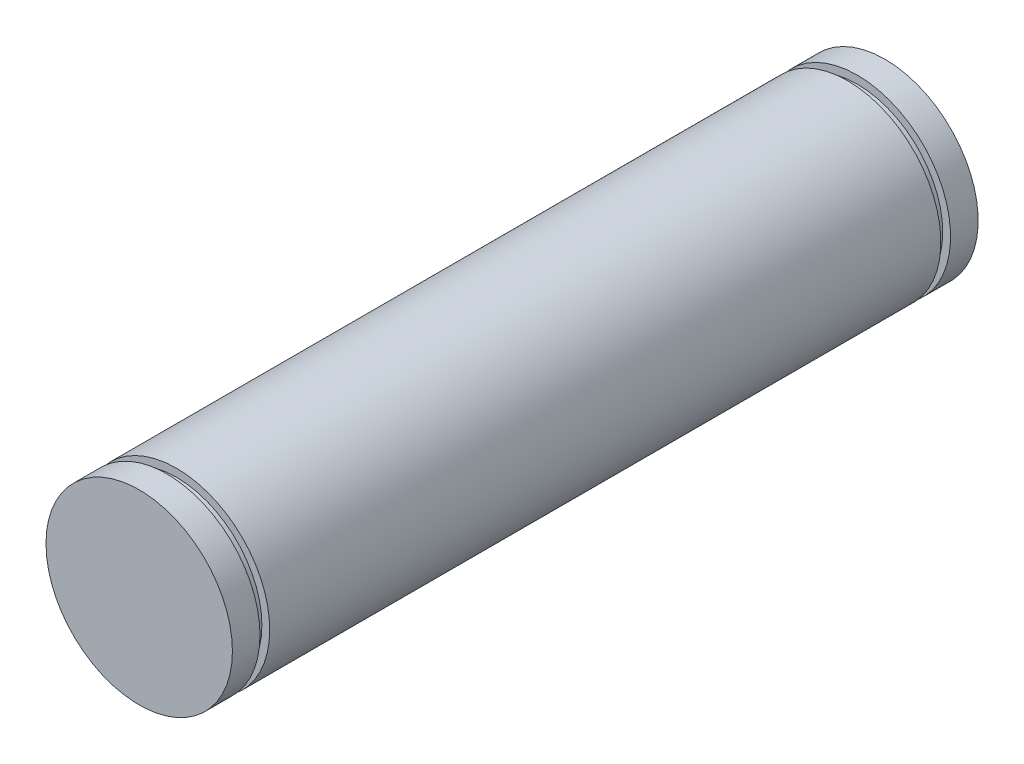
from build123d import *

# Parameters (mm, degrees)
SKETCH_1_R          = 12.5
EXTRUDE_1_DEPTH     = 5
SKETCH_1_2_R        = 12.5
EXTRUDE_2_DEPTH     = 95
SKETCH_2_OUTSIDE_W  = 48.214
SKETCH_2_OUTSIDE_H  = 48.214
SKETCH_2_OUTSIDE_R  = 11.45
CUT_EXTRUDE_1_DEPTH = 1.3
SKETCH_3_OUTSIDE_W  = 48.214
SKETCH_3_OUTSIDE_H  = 48.214
SKETCH_3_OUTSIDE_R  = 11.45
CUT_EXTRUDE_2_DEPTH = 1.3


with BuildPart() as part:
    # 草图1 → 凸台-拉伸1 (new body)
    with BuildSketch(Plane.XY.offset(5503)):
        with Locations((1309.324811799, 736.635546363)):
            Circle(SKETCH_1_R)
    extrude(amount=EXTRUDE_1_DEPTH)

    # 草图1<2> → 凸台-拉伸2 (add)
    with BuildSketch(Plane.XY.offset(5503)):
        with Locations((1309.324811799, 736.635546363)):
            Circle(SKETCH_1_2_R)
    extrude(amount=-EXTRUDE_2_DEPTH)

    # 草图2 outside → 切除-拉伸1 (cut)
    with BuildSketch(Plane.XY.offset(5503)):
        with Locations((1309.325, 736.636)):
            Rectangle(SKETCH_2_OUTSIDE_W, SKETCH_2_OUTSIDE_H)
        with Locations((1309.324811799, 736.635546363)):
            Circle(SKETCH_2_OUTSIDE_R, mode=Mode.SUBTRACT)
    extrude(amount=CUT_EXTRUDE_1_DEPTH, mode=Mode.SUBTRACT)

    # 草图3 outside → 切除-拉伸2 (cut)
    with BuildSketch(Plane(origin=(0, 0, 5413), x_dir=(-1, 0, 0), z_dir=(0, 0, -1))):
        with Locations((-1309.325, 736.636)):
            Rectangle(SKETCH_3_OUTSIDE_W, SKETCH_3_OUTSIDE_H)
        with Locations((-1309.324811799, 736.635546363)):
            Circle(SKETCH_3_OUTSIDE_R, mode=Mode.SUBTRACT)
    extrude(amount=CUT_EXTRUDE_2_DEPTH, mode=Mode.SUBTRACT)


solid = part.part
